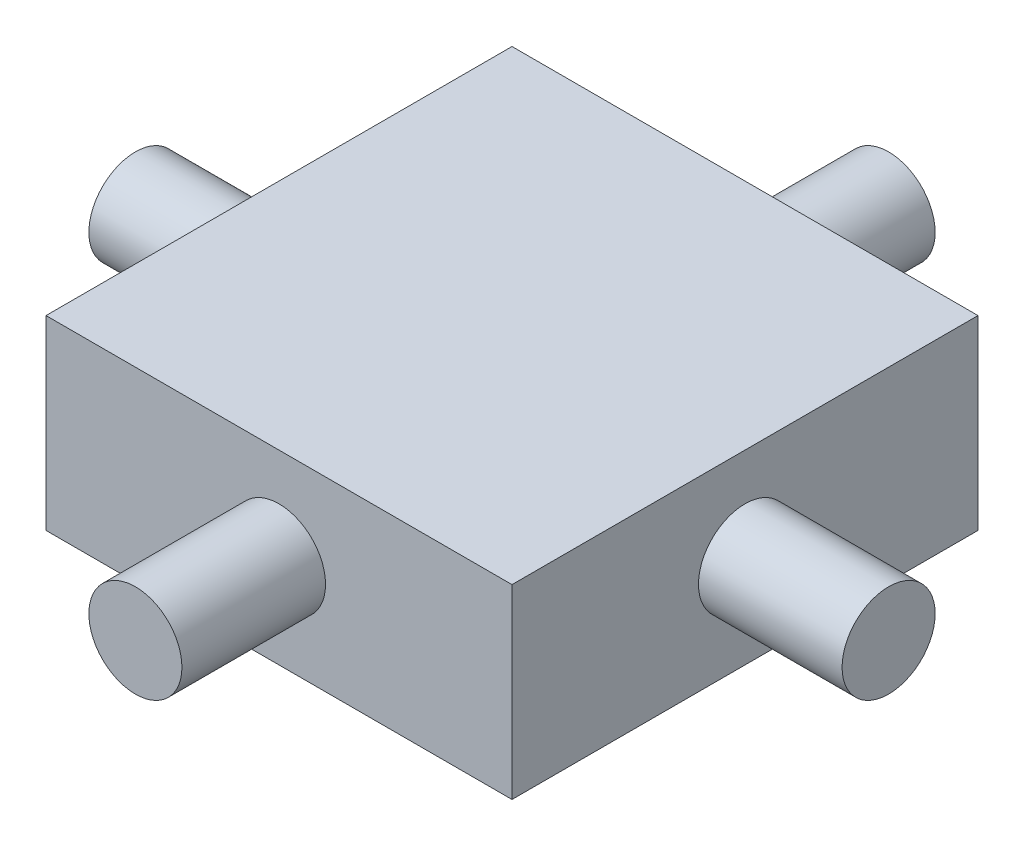
from build123d import *

# Parameters (mm, degrees)
SKETCH5_W           = 31.8
SKETCH5_H           = 12.7
BOSS_EXTRUDE4_DEPTH = 31.8
SKETCH6_R           = 3.175
BOSS_EXTRUDE5_DEPTH = 9.8
SKETCH10_R          = 3.175
BOSS_EXTRUDE6_DEPTH = 9.8


with BuildPart() as part:
    # Sketch5 → Boss-Extrude4 (new body)
    with BuildSketch(Plane.XY):
        with Locations((-44.843150914, -10.871383787)):
            Rectangle(SKETCH5_W, SKETCH5_H)
    extrude(amount=BOSS_EXTRUDE4_DEPTH)

    # Sketch6 → Boss-Extrude5 (add)
    with BuildSketch(Plane.XY.offset(31.8)):
        with Locations((-44.843150914, -10.871383787)):
            Circle(SKETCH6_R)
    boss_extrude5 = extrude(amount=BOSS_EXTRUDE5_DEPTH)

    # Mirror1: Boss-Extrude5 across plane
    add(boss_extrude5.mirror(Plane.XY.offset(15.9)))

    # Sketch10 → Boss-Extrude6 (add)
    with BuildSketch(Plane(origin=(-28.943150914, 0, 0), x_dir=(0, 0, -1), z_dir=(1, 0, 0))):
        with Locations((-15.9, -10.871383787)):
            Circle(SKETCH10_R)
    boss_extrude6 = extrude(amount=BOSS_EXTRUDE6_DEPTH)

    # Mirror2: Boss-Extrude6 across plane
    add(boss_extrude6.mirror(Plane(origin=(-44.843150914, 0, 0), x_dir=(0, 0, 1), z_dir=(1, 0, 0))))


solid = part.part
